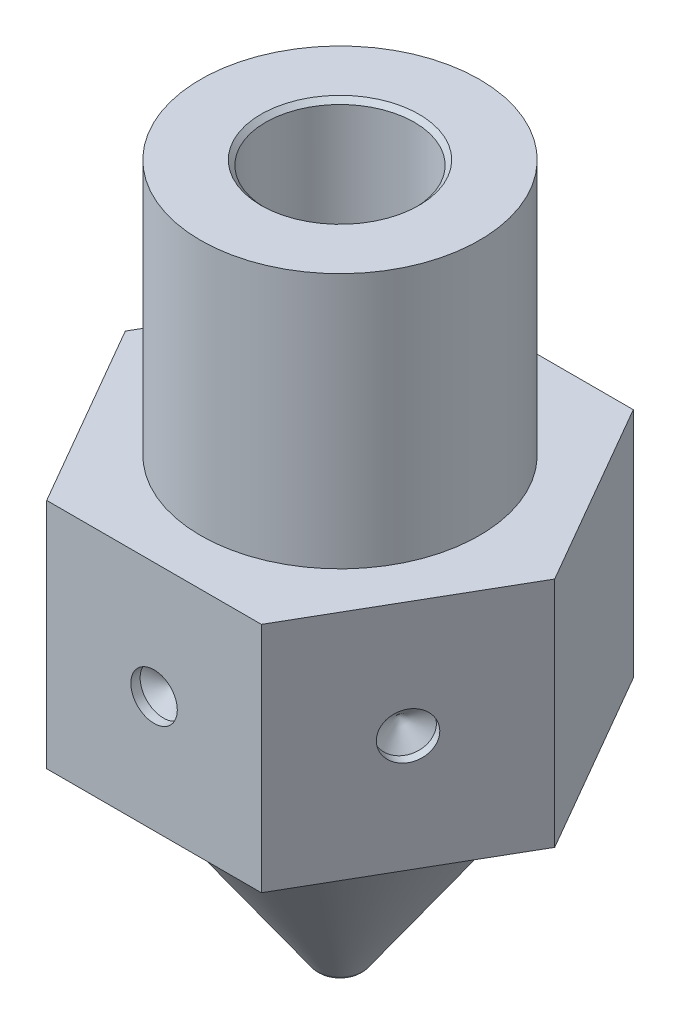
from build123d import *

# Parameters (mm, degrees)
CORTAR_EXTRUIR1_START                       = 1
CROQUIS2_R                                  = 7.058141728
CORTAR_EXTRUIR1_DEPTH                       = 7
CHAFL_N1_SIZE                               = 0.1
DI_METRO_DE_TALADRO_1_0_1_1_D               = 1
DI_METRO_DE_TALADRO_1_0_1_1_DEPTH           = 0.2
DI_METRO_DE_TALADRO_1_0_1_1_TIP             = 0.30043031
DI_METRO_DE_TALADRO_1_0_1_1_ON_FACE_2_D     = 1
DI_METRO_DE_TALADRO_1_0_1_1_ON_FACE_2_DEPTH = 0.2
DI_METRO_DE_TALADRO_1_0_1_1_ON_FACE_2_TIP   = 0.30043031


with BuildPart() as part:
    # Croquis1 → Revolución1 (revolve)
    with BuildSketch(Plane.XY):
        with BuildLine():
            Line((0.2, 0), (0.25, 0))
            ThreePointArc((0.25, 0), (0.388524584, 0.03389675), (0.495745613, 0.127927069))
            Line((0.495745613, 0.127927069), (3.557104037, 4.5))
            Line((3.557104037, 4.5), (5.706019053, 4.5))
            Line((5.706019053, 4.5), (5.706019053, 7.568968696))
            Line((5.706019053, 7.568968696), (7.058141728, 9.5))
            Line((7.058141728, 9.5), (3, 9.5))
            Line((3, 9.5), (3, 15))
            Line((3, 15), (1.6, 15))
            Line((1.6, 15), (1.6, 2.799407209))
            Line((1.6, 2.799407209), (0.2, 0.8))
            Line((0.2, 0.8), (0.2, 0))
        make_face()
    revolve(axis=Axis((0, 0, 0), (0, 1, 0)))

    # Croquis2 → Cortar-Extruir1 (cut)
    with BuildSketch(Plane(origin=(0, 9.5, 0), x_dir=(1, 0, 0), z_dir=(0, 1, 0)).offset(CORTAR_EXTRUIR1_START)):
        Circle(CROQUIS2_R)
        Polygon((2.309401077, 4), (-2.309401077, 4), (-4.618802154, 0), (-2.309401077, -4), (2.309401077, -4), (4.618802154, 0), align=None, mode=Mode.SUBTRACT)
    extrude(amount=-CORTAR_EXTRUIR1_DEPTH, mode=Mode.SUBTRACT)

    # Chaflán1
    chafl_n1_edges = [part.edges().sort_by_distance(p)[0] for p in [
        (-1.6, 15, 0),
    ]]
    chamfer(chafl_n1_edges, length=CHAFL_N1_SIZE)

    # Diámetro de taladro Ø1.0 (1)1
    with Locations(Plane(origin=(3.464101615, 7, 2), x_dir=(-0.5, 0, 0.866025404), z_dir=(0.866025404, 0, 0.5))):
        with Locations((0, 0)):
            Hole(DI_METRO_DE_TALADRO_1_0_1_1_D / 2, depth=DI_METRO_DE_TALADRO_1_0_1_1_DEPTH)
            with Locations((0, 0, -(DI_METRO_DE_TALADRO_1_0_1_1_DEPTH + DI_METRO_DE_TALADRO_1_0_1_1_TIP / 2))):  # 118° drill point
                Cone(0, DI_METRO_DE_TALADRO_1_0_1_1_D / 2, DI_METRO_DE_TALADRO_1_0_1_1_TIP, mode=Mode.SUBTRACT)

    # Diámetro de taladro Ø1.0 (1)1 on face 2
    with Locations(Plane(origin=(0, 7, 4), x_dir=(1, 0, 0), z_dir=(0, 0, 1))):
        with Locations((0, 0)):
            Hole(DI_METRO_DE_TALADRO_1_0_1_1_ON_FACE_2_D / 2, depth=DI_METRO_DE_TALADRO_1_0_1_1_ON_FACE_2_DEPTH)
            with Locations((0, 0, -(DI_METRO_DE_TALADRO_1_0_1_1_ON_FACE_2_DEPTH + DI_METRO_DE_TALADRO_1_0_1_1_ON_FACE_2_TIP / 2))):  # 118° drill point
                Cone(0, DI_METRO_DE_TALADRO_1_0_1_1_ON_FACE_2_D / 2, DI_METRO_DE_TALADRO_1_0_1_1_ON_FACE_2_TIP, mode=Mode.SUBTRACT)


solid = part.part
